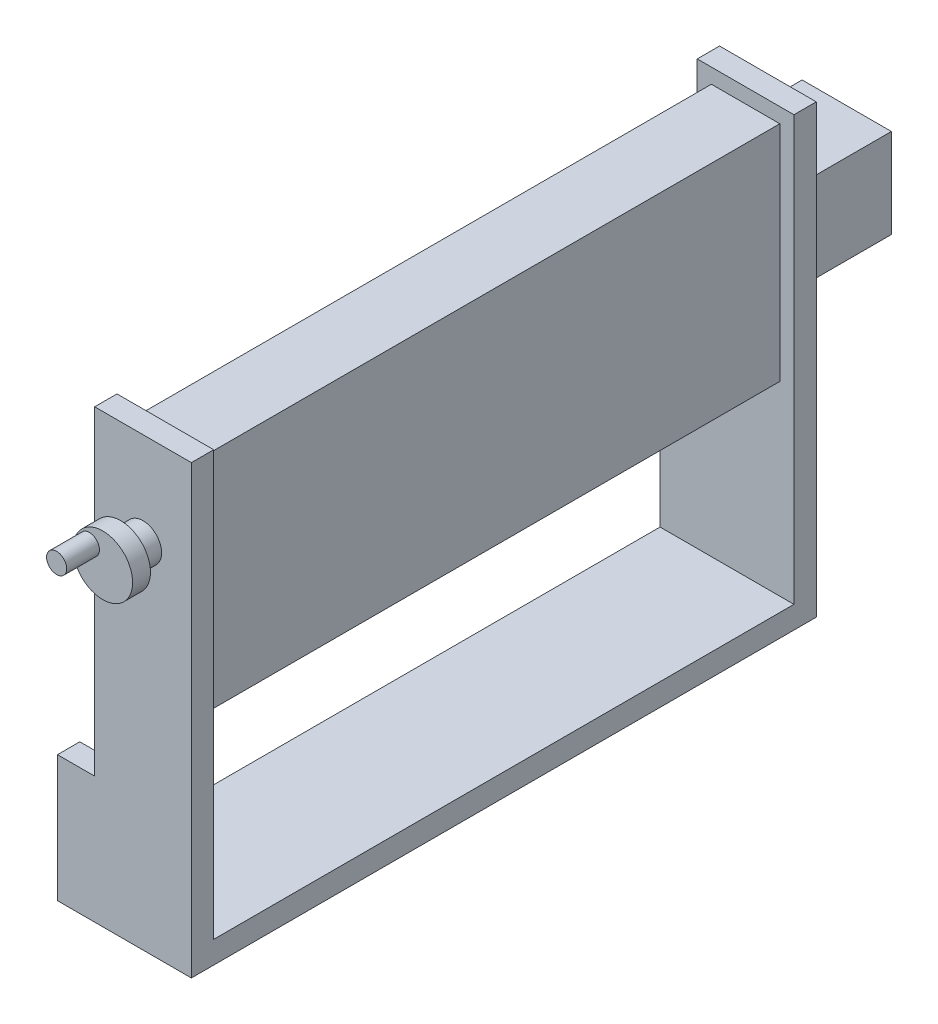
from build123d import *

# Parameters (mm, degrees)
EXTRUDE_1_DEPTH = 15
SKETCH_2_R      = 12.5
EXTRUDE_2_DEPTH = 15
SKETCH_3_R      = 20
EXTRUDE_3_DEPTH = 12
SKETCH_4_W      = 46
SKETCH_4_H      = 150
EXTRUDE_4_DEPTH = 390
EXTRUDE_5_DEPTH = 15
SKETCH_7_W      = 60
SKETCH_7_H      = 60
EXTRUDE_6_DEPTH = 53
EXTRUDE_7_REACH = 434
SKETCH_8_W      = 90
SKETCH_8_H      = 15
SKETCH_9_R      = 6.75806605
EXTRUDE_8_DEPTH = 22


with BuildPart() as part:
    # ｽｹｯﾁ1 → ﾎﾞｽ - 押し出し1 (new body)
    with BuildSketch(Plane.XY):
        Polygon((0, 0), (90, 0), (90, 300), (25, 300), (25, 85), (0, 85), align=None)
    extrude(amount=EXTRUDE_1_DEPTH)

    # ｽｹｯﾁ2 → ﾎﾞｽ - 押し出し2 (add)
    with BuildSketch(Plane.XY.offset(15)):
        with Locations((57.5, 237.462606559)):
            Circle(SKETCH_2_R)
    extrude(amount=EXTRUDE_2_DEPTH)

    # ｽｹｯﾁ3 → ﾎﾞｽ - 押し出し3 (add)
    with BuildSketch(Plane.XY.offset(30)):
        with Locations((57.5, 237.462606559)):
            Circle(SKETCH_3_R)
    extrude(amount=EXTRUDE_3_DEPTH)

    # ｽｹｯﾁ4 → ﾎﾞｽ - 押し出し4 (add)
    with BuildSketch(Plane(origin=(0, 0, 0), x_dir=(-1, 0, 0), z_dir=(0, 0, -1))):
        with Locations((-57.5, 215)):
            Rectangle(SKETCH_4_W, SKETCH_4_H)
    extrude(amount=EXTRUDE_4_DEPTH)

    # ｽｹｯﾁ6 → ﾎﾞｽ - 押し出し5 (add)
    with BuildSketch(Plane(origin=(0, 0, -390), x_dir=(-1, 0, 0), z_dir=(0, 0, -1))):
        Polygon((-90, 300), (-25, 300), (-25, 85), (0, 85), (0, 0), (-90, 0), align=None)
    extrude(amount=EXTRUDE_5_DEPTH)

    # ｽｹｯﾁ7 → ﾎﾞｽ - 押し出し6 (add)
    with BuildSketch(Plane(origin=(0, 0, -405), x_dir=(-1, 0, 0), z_dir=(0, 0, -1))):
        with Locations((-57.5, 225)):
            Rectangle(SKETCH_7_W, SKETCH_7_H)
    extrude(amount=EXTRUDE_6_DEPTH)

    # ｽｹｯﾁ8 → ﾎﾞｽ - 押し出し7 (add, up to next)
    with BuildSketch(Plane.XY.offset(-390), mode=Mode.PRIVATE) as extrude_7_sk1:
        with Locations((45, 7.5)):
            Rectangle(SKETCH_8_W, SKETCH_8_H)
    extrude_7_tool1 = extrude(extrude_7_sk1.sketch, amount=EXTRUDE_7_REACH, mode=Mode.PRIVATE) - part.part
    add(extrude_7_tool1.solids().sort_by_distance((45, 7.5, -390))[0])

    # ｽｹｯﾁ9 → ﾎﾞｽ - 押し出し8 (add)
    with BuildSketch(Plane.XY.offset(42)):
        with Locations((48.443492705, 245.308936779)):
            Circle(SKETCH_9_R)
    extrude(amount=EXTRUDE_8_DEPTH)


solid = part.part
